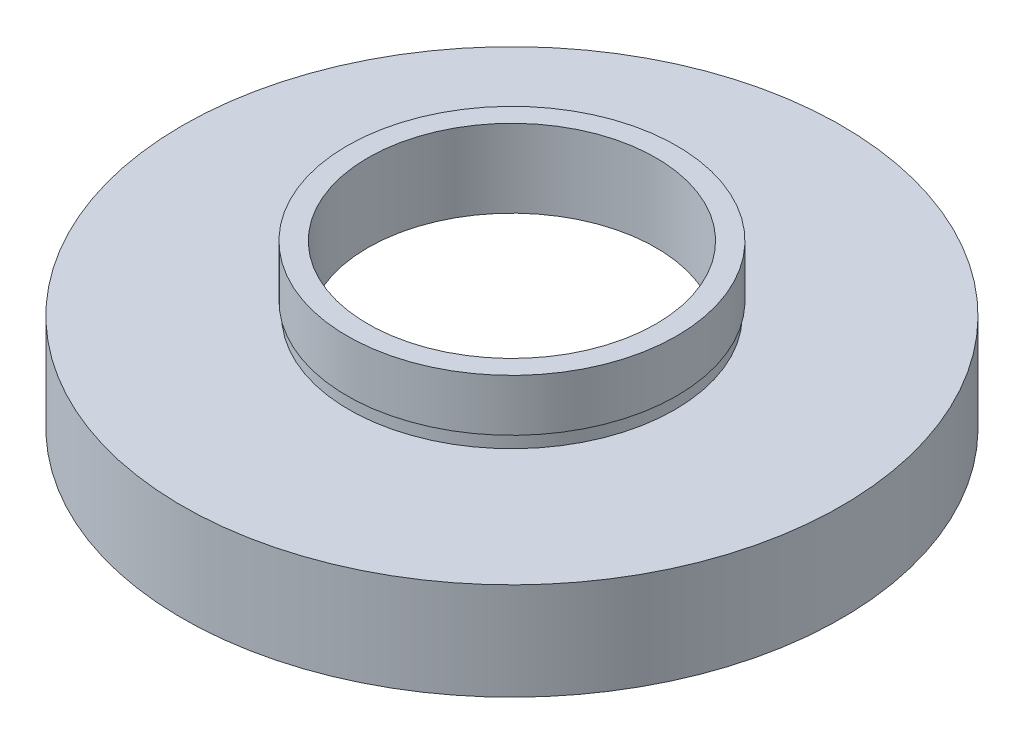
from build123d import *


with BuildPart() as part:
    # 草图1 → 旋转1 (revolve)
    with BuildSketch(Plane.XY, mode=Mode.PRIVATE) as revolve_1_sk:
        Polygon((23.5, 0), (23.5, 5.5), (24.1, 5.5), (24.1, 6.5), (11.1, 6.5), (11.1, 12.5), (12.7, 12.5), (12.7, 8.5), (12.55, 8.5), (12.55, 7.5), (25.4, 7.5), (25.4, 0), align=None)
    revolve(revolve_1_sk.sketch.rotate(Axis((0, 16.886018237, 0), (0, -1, 0)), 180), axis=Axis((0, 16.886018237, 0), (0, -1, 0)))  # turned: the seam where the file's is


solid = part.part
